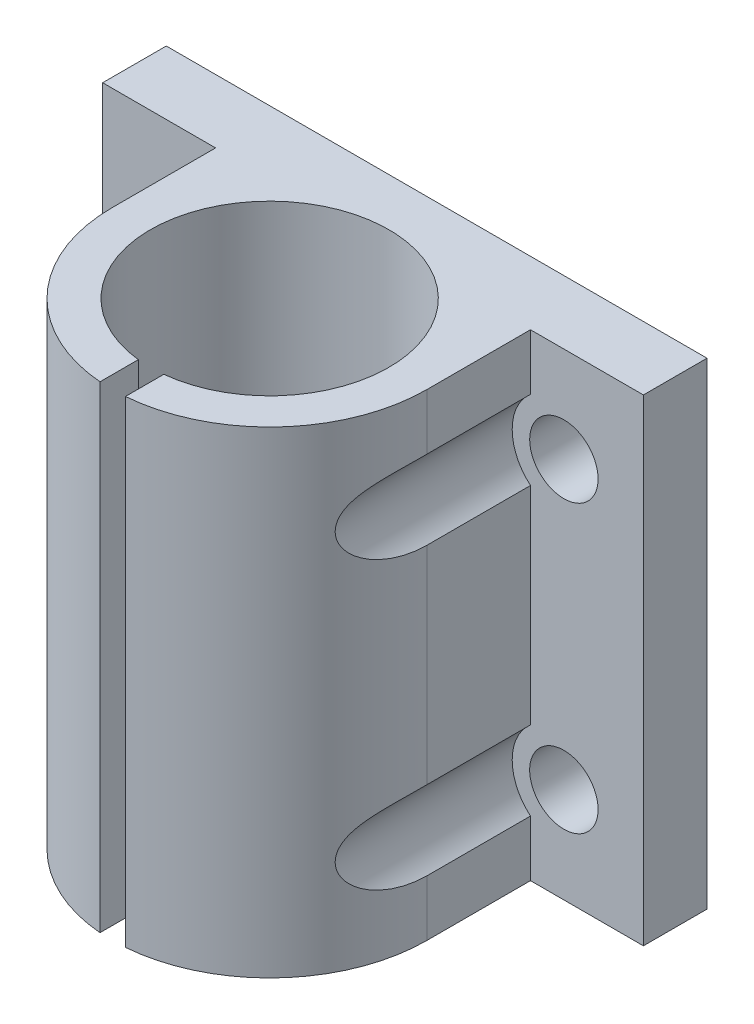
from build123d import *

# Parameters (mm, degrees)
BOSS_EXTRUDE1_DEPTH      = 15
BOSS_EXTRUDE1_DEPTH_BACK = 15
CUT_EXTRUDE1_REACH       = 22.368
SKETCH2_R                = 2.15
CUT_EXTRUDE2_REACH       = 26.368
CUT_EXTRUDE2_START       = -4
SKETCH3_R                = 3.25


with BuildPart() as part:
    # Sketch1 → Boss-Extrude1 (new body, two sides)
    with BuildSketch(Plane(origin=(0, 0, 0), x_dir=(1, 0, 0), z_dir=(0, 1, 0))) as boss_extrude1_sk:
        with BuildLine():
            Line((-9.9, 6.5), (-9.9, 0))
            ThreePointArc((-9.9, 0), (-7.277705682, -6.711557196), (-0.8, -9.867623827))
            Line((-0.8, -9.867623827), (-0.8, -7.457211275))
            ThreePointArc((-0.8, -7.457211275), (0, 7.5), (0.8, -7.457211275))
            Line((0.8, -7.457211275), (0.8, -9.867623827))
            ThreePointArc((0.8, -9.867623827), (7.277705682, -6.711557196), (9.9, 0))
            Line((9.9, 0), (9.9, 6.5))
            Line((9.9, 6.5), (17, 6.5))
            Line((17, 6.5), (17, 10.5))
            Line((17, 10.5), (-17, 10.5))
            Line((-17, 10.5), (-17, 6.5))
            Line((-17, 6.5), (-9.9, 6.5))
        make_face()
    extrude(amount=BOSS_EXTRUDE1_DEPTH)
    extrude(boss_extrude1_sk.sketch, amount=-BOSS_EXTRUDE1_DEPTH_BACK)

    # Sketch2 → Cut-Extrude1 (cut, up to next)
    with BuildSketch(Plane(origin=(0, 0, -10.5), x_dir=(-1, 0, 0), z_dir=(0, 0, -1)), mode=Mode.PRIVATE) as cut_extrude1_sk1:
        with Locations((12, -9)):
            Circle(SKETCH2_R)
    cut_extrude1_tool1 = extrude(cut_extrude1_sk1.sketch, amount=-CUT_EXTRUDE1_REACH, mode=Mode.PRIVATE) & part.part
    add(cut_extrude1_tool1.solids().sort_by_distance((-12, -9, -10.5))[0], mode=Mode.SUBTRACT)
    # Sketch2 → Cut-Extrude1 (cut, up to next)
    with BuildSketch(Plane(origin=(0, 0, -10.5), x_dir=(-1, 0, 0), z_dir=(0, 0, -1)), mode=Mode.PRIVATE) as cut_extrude1_sk2:
        with Locations((-12, -9)):
            Circle(SKETCH2_R)
    cut_extrude1_tool2 = extrude(cut_extrude1_sk2.sketch, amount=-CUT_EXTRUDE1_REACH, mode=Mode.PRIVATE) & part.part
    add(cut_extrude1_tool2.solids().sort_by_distance((12, -9, -10.5))[0], mode=Mode.SUBTRACT)
    # Sketch2 → Cut-Extrude1 (cut, up to next)
    with BuildSketch(Plane(origin=(0, 0, -10.5), x_dir=(-1, 0, 0), z_dir=(0, 0, -1)), mode=Mode.PRIVATE) as cut_extrude1_sk3:
        with Locations((-12, 9)):
            Circle(SKETCH2_R)
    cut_extrude1_tool3 = extrude(cut_extrude1_sk3.sketch, amount=-CUT_EXTRUDE1_REACH, mode=Mode.PRIVATE) & part.part
    add(cut_extrude1_tool3.solids().sort_by_distance((12, 9, -10.5))[0], mode=Mode.SUBTRACT)
    # Sketch2 → Cut-Extrude1 (cut, up to next)
    with BuildSketch(Plane(origin=(0, 0, -10.5), x_dir=(-1, 0, 0), z_dir=(0, 0, -1)), mode=Mode.PRIVATE) as cut_extrude1_sk4:
        with Locations((12, 9)):
            Circle(SKETCH2_R)
    cut_extrude1_tool4 = extrude(cut_extrude1_sk4.sketch, amount=-CUT_EXTRUDE1_REACH, mode=Mode.PRIVATE) & part.part
    add(cut_extrude1_tool4.solids().sort_by_distance((-12, 9, -10.5))[0], mode=Mode.SUBTRACT)

    # Sketch3 → Cut-Extrude2 (cut, up to next)
    with BuildSketch(Plane(origin=(0, 0, -10.5), x_dir=(-1, 0, 0), z_dir=(0, 0, -1)).offset(CUT_EXTRUDE2_START), mode=Mode.PRIVATE) as cut_extrude2_sk1:
        with Locations((-12, 9)):
            Circle(SKETCH3_R)
    cut_extrude2_tool1 = extrude(cut_extrude2_sk1.sketch, amount=-CUT_EXTRUDE2_REACH, mode=Mode.PRIVATE) & part.part
    add(cut_extrude2_tool1.solids().sort_by_distance((12, 9, -6.5))[0], mode=Mode.SUBTRACT)
    # Sketch3 → Cut-Extrude2 (cut, up to next)
    with BuildSketch(Plane(origin=(0, 0, -10.5), x_dir=(-1, 0, 0), z_dir=(0, 0, -1)).offset(CUT_EXTRUDE2_START), mode=Mode.PRIVATE) as cut_extrude2_sk2:
        with Locations((-12, -9)):
            Circle(SKETCH3_R)
    cut_extrude2_tool2 = extrude(cut_extrude2_sk2.sketch, amount=-CUT_EXTRUDE2_REACH, mode=Mode.PRIVATE) & part.part
    add(cut_extrude2_tool2.solids().sort_by_distance((12, -9, -6.5))[0], mode=Mode.SUBTRACT)
    # Sketch3 → Cut-Extrude2 (cut, up to next)
    with BuildSketch(Plane(origin=(0, 0, -10.5), x_dir=(-1, 0, 0), z_dir=(0, 0, -1)).offset(CUT_EXTRUDE2_START), mode=Mode.PRIVATE) as cut_extrude2_sk3:
        with Locations((12, 9)):
            Circle(SKETCH3_R)
    cut_extrude2_tool3 = extrude(cut_extrude2_sk3.sketch, amount=-CUT_EXTRUDE2_REACH, mode=Mode.PRIVATE) & part.part
    add(cut_extrude2_tool3.solids().sort_by_distance((-12, 9, -6.5))[0], mode=Mode.SUBTRACT)
    # Sketch3 → Cut-Extrude2 (cut, up to next)
    with BuildSketch(Plane(origin=(0, 0, -10.5), x_dir=(-1, 0, 0), z_dir=(0, 0, -1)).offset(CUT_EXTRUDE2_START), mode=Mode.PRIVATE) as cut_extrude2_sk4:
        with Locations((12, -9)):
            Circle(SKETCH3_R)
    cut_extrude2_tool4 = extrude(cut_extrude2_sk4.sketch, amount=-CUT_EXTRUDE2_REACH, mode=Mode.PRIVATE) & part.part
    add(cut_extrude2_tool4.solids().sort_by_distance((-12, -9, -6.5))[0], mode=Mode.SUBTRACT)


solid = part.part
